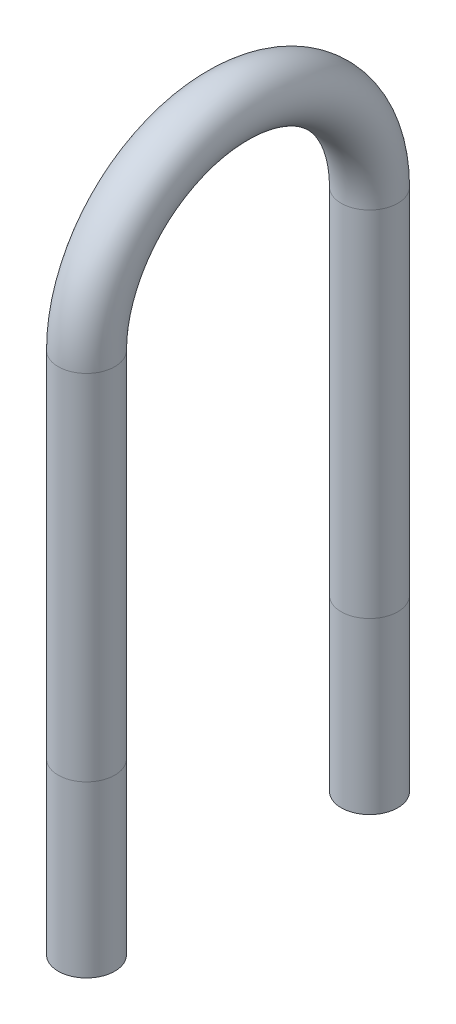
from build123d import *

# Parameters (mm, degrees)
SKETCH2_R   = 25.4
SKETCH2_R_2 = 23.749


with BuildPart() as part:
    # Sweep1: sweep along a path in Sketch1
    with BuildLine(Plane(origin=(0, 0, 0), x_dir=(0, 0, -1), z_dir=(1, 0, 0))) as sweep1_path:
        Line((0, -152.4), (0, 0))
        Line((0, 0), (0, 317.5))
        ThreePointArc((0, 317.5), (127, 444.5), (254, 317.5))
        Line((254, 317.5), (254, 0))
        Line((254, 0), (254, -152.4))
    # Sketch2 → Sweep1 (sweep)
    with BuildSketch(Plane(origin=(0, -152.4, 0), x_dir=(1, 0, 0), z_dir=(0, 1, 0))):
        Circle(SKETCH2_R)
        Circle(SKETCH2_R_2, mode=Mode.SUBTRACT)
    sweep(path=sweep1_path.line)


solid = part.part
